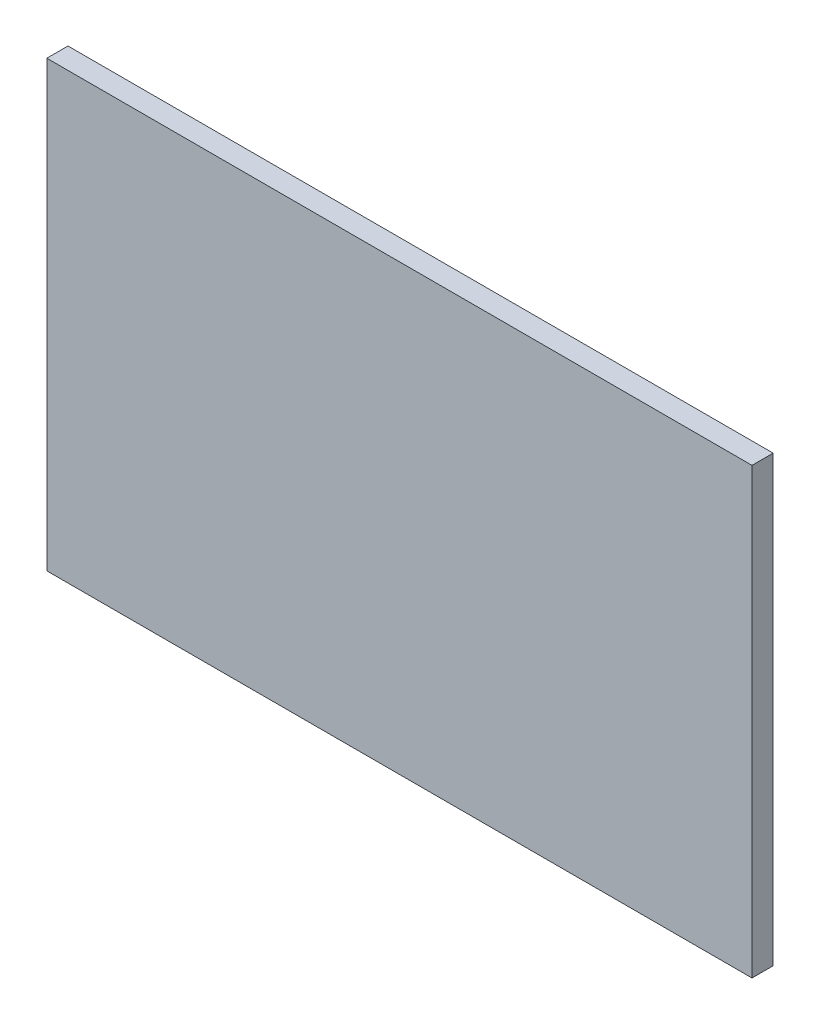
from build123d import *

# Parameters (mm, degrees)
SKETCH1_W           = 1115
SKETCH1_H           = 702
BOSS_EXTRUDE1_DEPTH = 33.45


with BuildPart() as part:
    # Sketch1 → Boss-Extrude1 (new body)
    with BuildSketch(Plane.XY):
        Rectangle(SKETCH1_W, SKETCH1_H)
    extrude(amount=BOSS_EXTRUDE1_DEPTH)


solid = part.part
